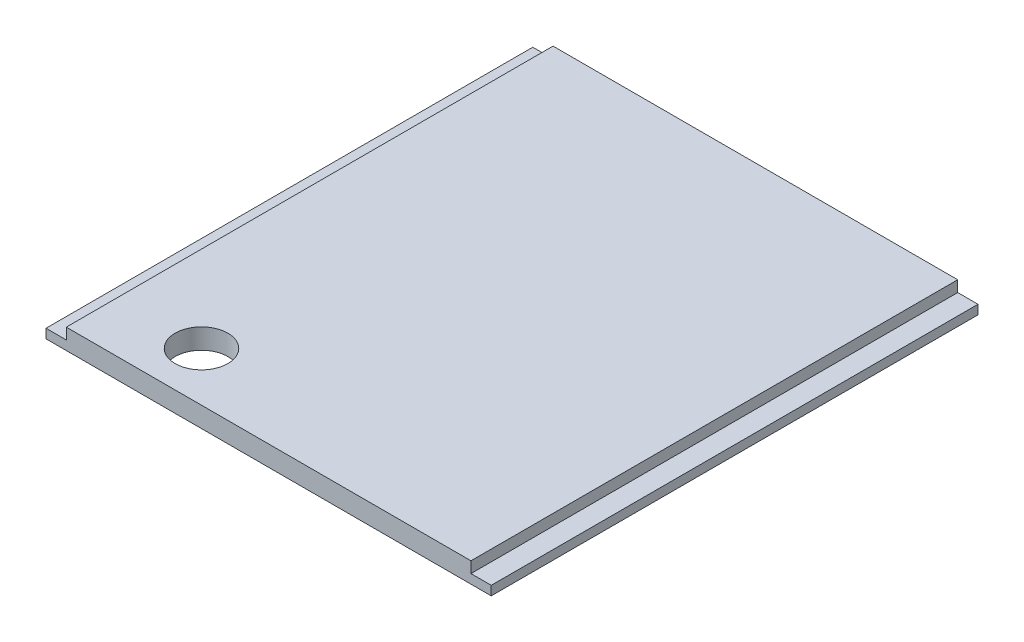
from build123d import *

# Parameters (mm, degrees)
SKETCH1_W           = 139.40028
SKETCH1_H           = 152.4
BOSS_EXTRUDE1_DEPTH = 6.35
SKETCH2_W           = 6.35
SKETCH2_H           = 152.4
CUT_EXTRUDE1_DEPTH  = 3.47472
SKETCH3_R           = 8.255
CUT_EXTRUDE2_DEPTH  = 7.35


with BuildPart() as part:
    # Sketch1 → Boss-Extrude1 (new body)
    with BuildSketch(Plane(origin=(0, 0, 0), x_dir=(1, 0, 0), z_dir=(0, 1, 0))):
        with Locations((69.70014, 76.2)):
            Rectangle(SKETCH1_W, SKETCH1_H)
    extrude(amount=BOSS_EXTRUDE1_DEPTH)

    # Sketch2 → Cut-Extrude1 (cut)
    with BuildSketch(Plane(origin=(0, 6.35, 0), x_dir=(1, 0, 0), z_dir=(0, 1, 0))):
        with Locations((3.175, 76.2)):
            Rectangle(SKETCH2_W, SKETCH2_H)
        with Locations((136.22528, 76.2)):
            Rectangle(SKETCH2_W, SKETCH2_H)
    extrude(amount=-CUT_EXTRUDE1_DEPTH, mode=Mode.SUBTRACT)

    # Sketch3 → Cut-Extrude2 (cut, through all)
    with BuildSketch(Plane(origin=(0, 6.35, 0), x_dir=(1, 0, 0), z_dir=(0, 1, 0))):
        with Locations((33.274, 15.408402902)):
            Circle(SKETCH3_R)
    extrude(amount=-CUT_EXTRUDE2_DEPTH, mode=Mode.SUBTRACT)


solid = part.part
